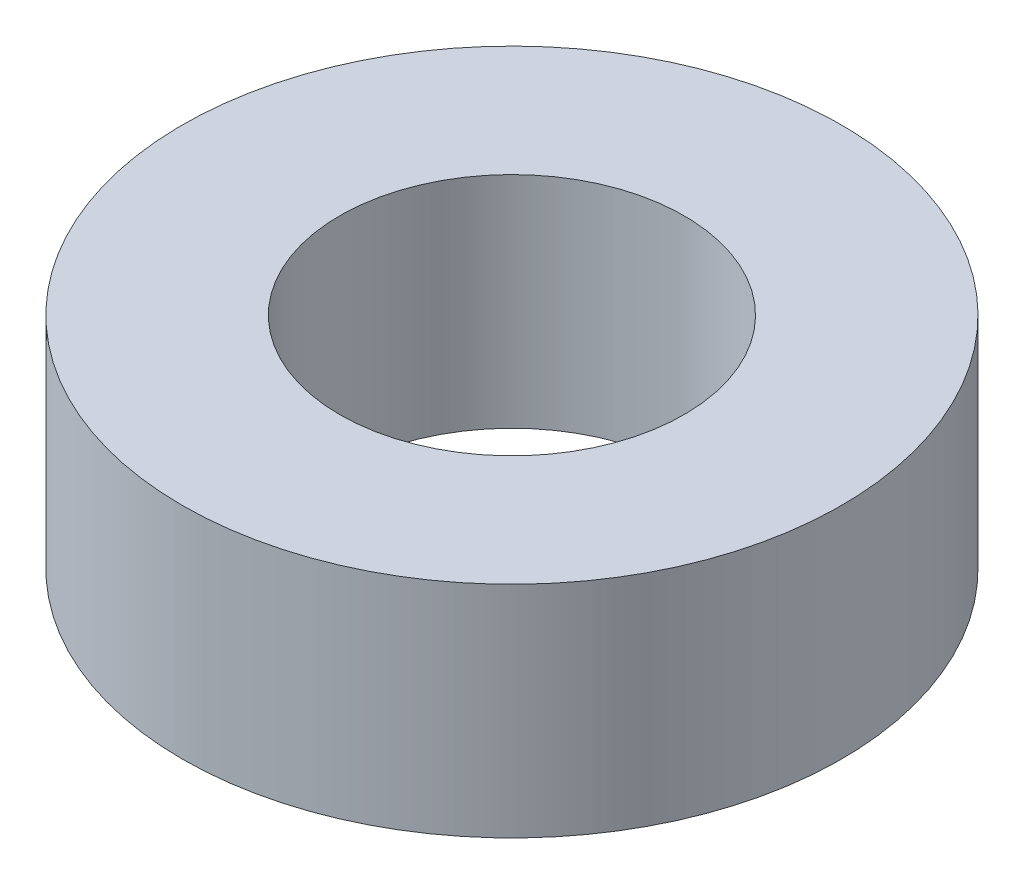
from build123d import *

# Parameters (mm, degrees)
SKETCH1_R           = 4.7625
SKETCH1_R_2         = 2.4892
BOSS_EXTRUDE1_DEPTH = 3.175


with BuildPart() as part:
    # Sketch1 → Boss-Extrude1 (new body)
    with BuildSketch(Plane(origin=(0, 0, 0), x_dir=(1, 0, 0), z_dir=(0, 1, 0))):
        Circle(SKETCH1_R)
        Circle(SKETCH1_R_2, mode=Mode.SUBTRACT)
    extrude(amount=BOSS_EXTRUDE1_DEPTH)


solid = part.part
